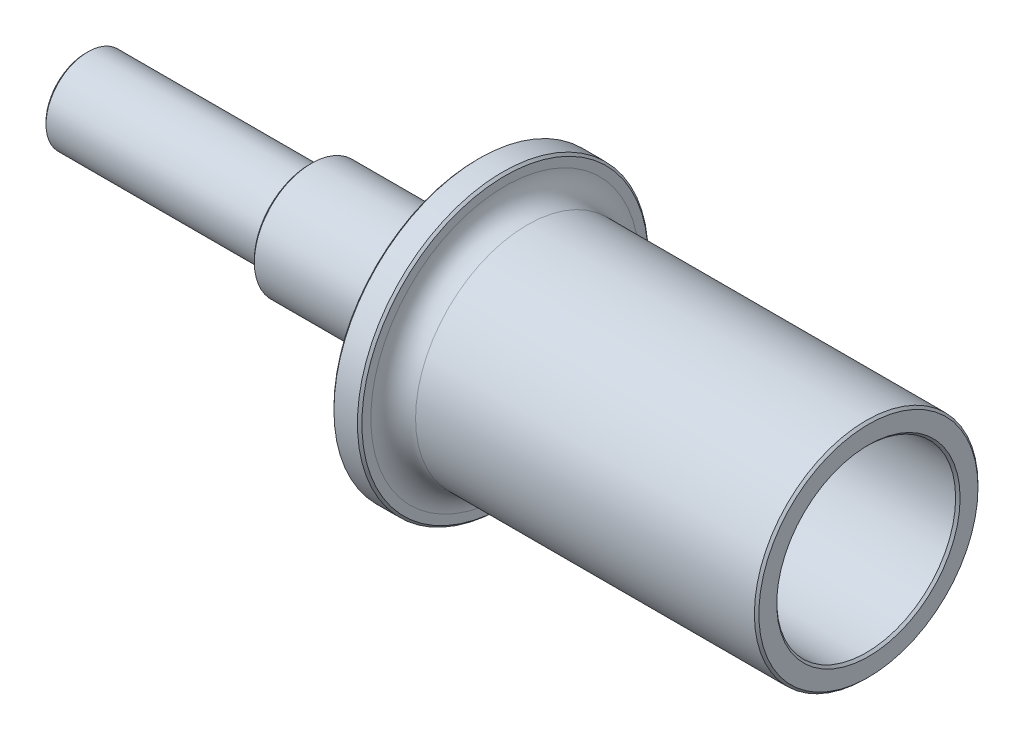
from build123d import *

# Parameters (mm, degrees)
FILLET2_R     = 0.75
CHAMFER1_SIZE = 0.254


with BuildPart() as part:
    # Sketch1 → Revolve1 (revolve)
    with BuildSketch(Plane(origin=(0, 0, 0), x_dir=(1, 0, 0), z_dir=(0, 1, 0))):
        with BuildLine():
            Line((6.35, 10.16), (-31.636489348, 10.16))
            ThreePointArc((-31.636489348, 10.16), (-33.432540572, 9.416051224), (-34.176489348, 7.62))
            Line((-34.176489348, 7.62), (-34.176489348, 0))
            Line((-34.176489348, 0), (-82.55, 0))
            Line((-82.55, 0), (-82.55, 4.7625))
            Line((-82.55, 4.7625), (-57.15, 4.7625))
            Line((-57.15, 4.7625), (-57.15, 6.5))
            Line((-57.15, 6.5), (-38.1, 6.5))
            Line((-38.1, 6.5), (-38.1, 16.51))
            Line((-38.1, 16.51), (-34.925, 16.51))
            Line((-34.925, 16.51), (-34.925, 15.24))
            ThreePointArc((-34.925, 15.24), (-34.181051224, 13.443948776), (-32.385, 12.7))
            Line((-32.385, 12.7), (6.35, 12.7))
            Line((6.35, 12.7), (6.35, 10.16))
        make_face()
    revolve(axis=Axis((0, 0, 0), (-1, 0, 0)))

    # Fillet2
    fillet2_edges = [part.edges().sort_by_distance(p)[0] for p in [
        (-57.15, 0, 4.7625),
        (-38.1, 0, 6.5),
    ]]
    fillet(fillet2_edges, radius=FILLET2_R)

    # Chamfer1
    chamfer1_edges = [part.edges().sort_by_distance(p)[0] for p in [
        (-57.15, 0, 6.5),
        (-38.1, 0, 16.51),
        (-34.925, 0, 16.51),
        (6.35, 0, 12.7),
        (6.35, 0, 10.16),
        (-82.55, 0, 4.7625),
    ]]
    chamfer(chamfer1_edges, length=CHAMFER1_SIZE)


solid = part.part
